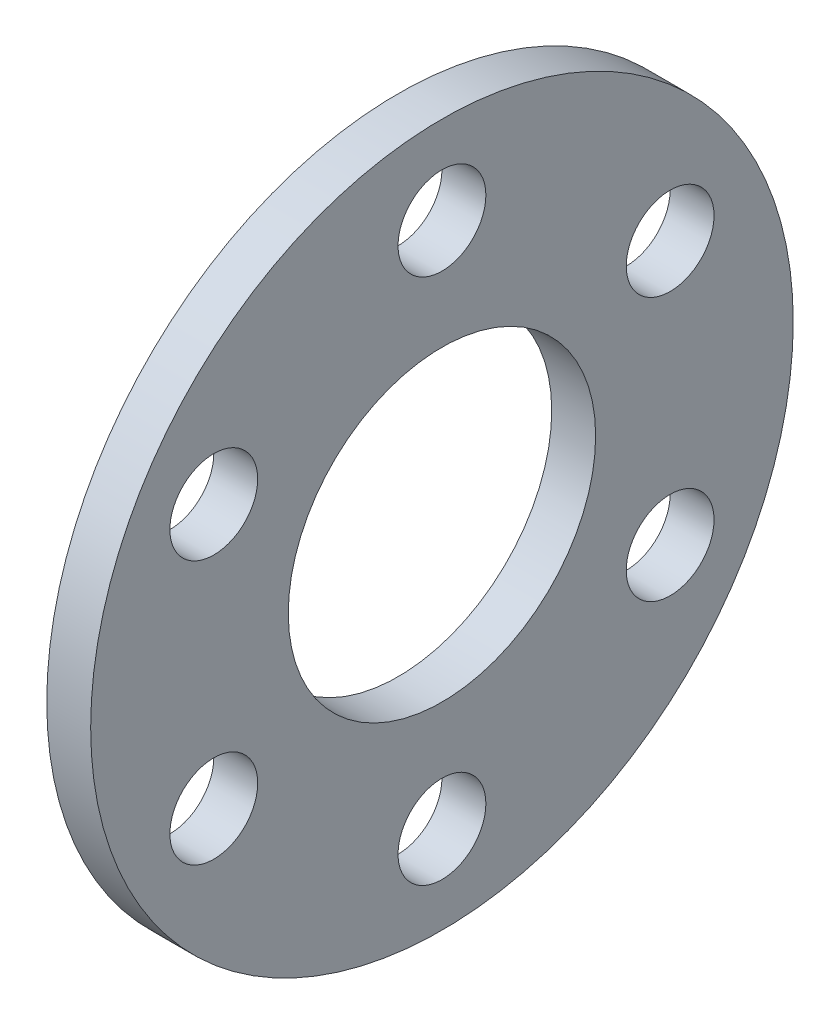
from build123d import *

# Parameters (mm, degrees)
SKETCH_1_R      = 24
SKETCH_1_R_2    = 10.5
SKETCH_1_R_3    = 3
EXTRUDE_1_DEPTH = 3


with BuildPart() as part:
    # 草图1 → 凸台-拉伸1 (new body)
    with BuildSketch(Plane(origin=(0, 0, 0), x_dir=(0, 0, -1), z_dir=(1, 0, 0))):
        Circle(SKETCH_1_R)
        Circle(SKETCH_1_R_2, mode=Mode.SUBTRACT)
        with Locations((-15.588457268, 9)):
            Circle(SKETCH_1_R_3, mode=Mode.SUBTRACT)
        with Locations((0, 18)):
            Circle(SKETCH_1_R_3, mode=Mode.SUBTRACT)
        with Locations((15.588457268, 9)):
            Circle(SKETCH_1_R_3, mode=Mode.SUBTRACT)
        with Locations((15.588457268, -9)):
            Circle(SKETCH_1_R_3, mode=Mode.SUBTRACT)
        with Locations((0, -18)):
            Circle(SKETCH_1_R_3, mode=Mode.SUBTRACT)
        with Locations((-15.588457268, -9)):
            Circle(SKETCH_1_R_3, mode=Mode.SUBTRACT)
    extrude(amount=EXTRUDE_1_DEPTH)


solid = part.part
